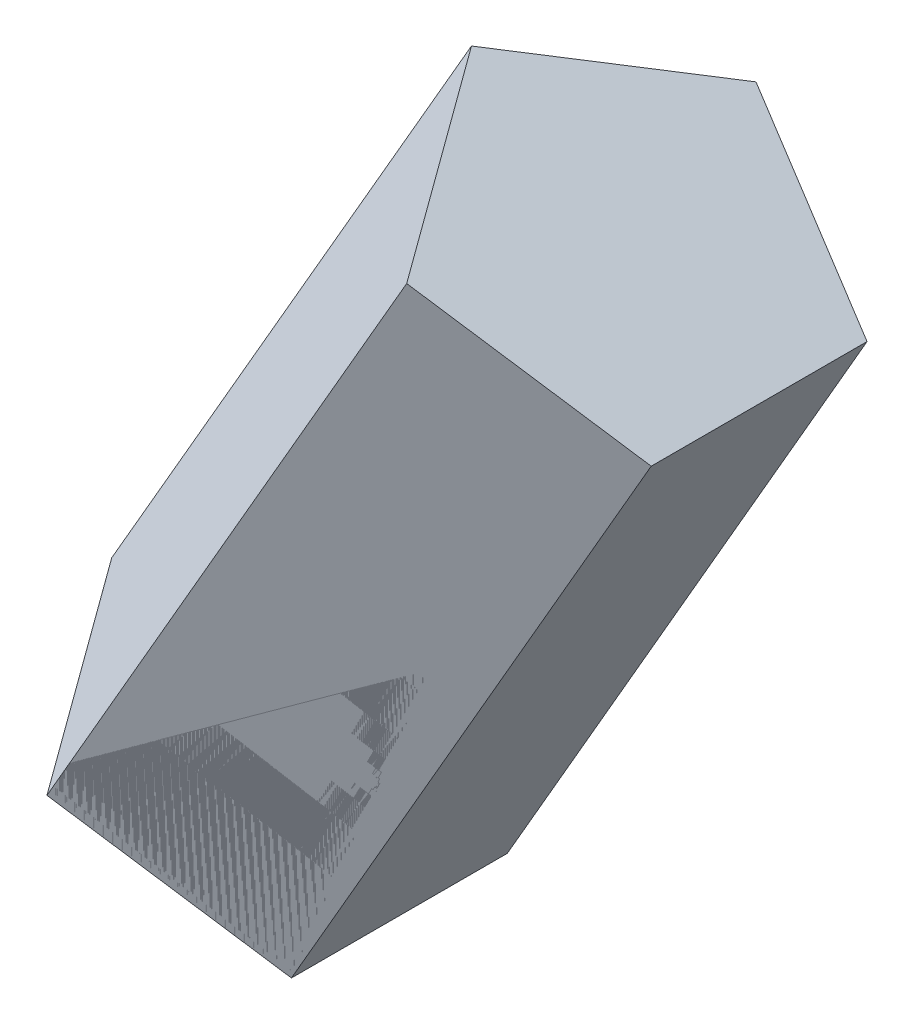
from build123d import *

# Parameters (mm, degrees)
BOSS_EXTRUDE2_DEPTH = 100
BOSS_EXTRUDE3_DEPTH = 100


with BuildPart() as part:
    # Sketch6 → Boss-Extrude2 (new body)
    with BuildSketch(Plane(origin=(32.5, 56.291651246, 0), x_dir=(-0.866025404, 0.5, 0), z_dir=(-0.5, -0.866025404, 0))):
        Polygon((-84.051607003, -74.270509831), (-66.418049434, -50), (-84.051607003, -25.729490169), (-112.583302492, -35), (-112.583302492, -65), align=None)
    extrude(amount=-BOSS_EXTRUDE2_DEPTH)

    # SurfaceCut1
    split(bisect_by=Plane(origin=(0, 0, 0), x_dir=(-0.890486908, -0.432473198, -0.141421356), z_dir=(0.447213595, -0.774596669, -0.447213595)), keep=Keep.TOP)


with BuildPart() as body_2:
    # Sketch7 → Boss-Extrude3 (new body)
    with BuildSketch(Plane(origin=(32.5, 56.291651246, 0), x_dir=(-0.866025404, 0.5, 0), z_dir=(-0.5, -0.866025404, 0))):
        Polygon((-66.418049434, -50), (-84.051607003, -25.729490169), (-112.583302492, -35), (-112.583302492, -65), (-84.051607003, -74.270509831), align=None)
    extrude(amount=-BOSS_EXTRUDE3_DEPTH)


solid = Compound([part.part, body_2.part])
